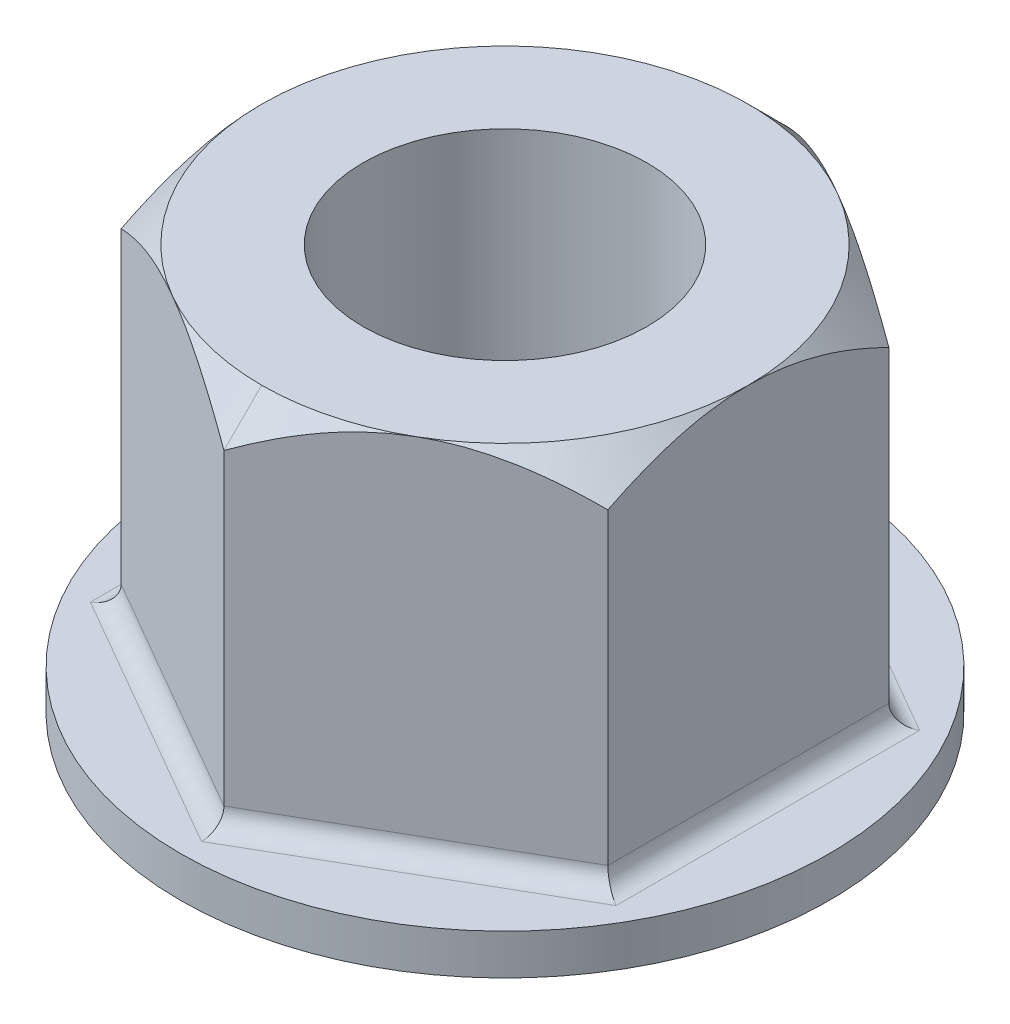
from build123d import *

# Parameters (mm, degrees)
SKETCH2_R                = 25.4
BOSS_EXTRUDE1_DEPTH      = 3.175
BOSS_EXTRUDE2_DEPTH      = 28.575
F_1_8_TAPPED_HOLE1_D     = 22.225
F_1_8_TAPPED_HOLE1_DEPTH = 31.75
FILLET1_R                = 1.524


with BuildPart() as part:
    # Sketch2 → Boss-Extrude1 (new body)
    with BuildSketch(Plane(origin=(0, 0, 0), x_dir=(1, 0, 0), z_dir=(0, 1, 0))):
        Circle(SKETCH2_R)
    extrude(amount=BOSS_EXTRUDE1_DEPTH)

    # Sketch3 → Boss-Extrude2 (add)
    with BuildSketch(Plane(origin=(0, 3.175, 0), x_dir=(1, 0, 0), z_dir=(0, 1, 0))):
        Polygon((0, 21.997045256), (-19.05, 10.998522628), (-19.05, -10.998522628), (0, -21.997045256), (19.05, -10.998522628), (19.05, 10.998522628), align=None)
    extrude(amount=BOSS_EXTRUDE2_DEPTH)

    # 1-8 Tapped Hole1
    with Locations(Plane(origin=(0, 31.75, 0), x_dir=(1, 0, 0), z_dir=(0, 1, 0))):
        with Locations((0, 0)):
            Hole(F_1_8_TAPPED_HOLE1_D / 2, depth=F_1_8_TAPPED_HOLE1_DEPTH)

    # Cut-Sweep1: sweep along a path in Sketch7
    with BuildLine(Plane(origin=(0, 31.75, 0), x_dir=(1, 0, 0), z_dir=(0, 1, 0))) as cut_sweep1_path:
        CenterArc((0, 0), 19.05, 0, 360)
    # Sketch8 → Cut-Sweep1 (sweep, cut)
    with BuildSketch(Plane(origin=(0, 0, 0), x_dir=(0, 0, -1), z_dir=(1, 0, 0))):
        Polygon((-21.997045256, 28.802954744), (-21.997045256, 31.75), (-19.05, 31.75), align=None)
    sweep(path=cut_sweep1_path.line, mode=Mode.SUBTRACT)

    # Fillet1
    fillet1_edges = [part.edges().sort_by_distance(p)[0] for p in [
        (9.525, 3.175, -16.497783942),
        (-9.525, 3.175, -16.497783942),
        (-19.05, 3.175, 0),
        (-9.525, 3.175, 16.497783942),
        (9.525, 3.175, 16.497783942),
        (19.05, 3.175, 0),
    ]]
    fillet(fillet1_edges, radius=FILLET1_R)


solid = part.part
